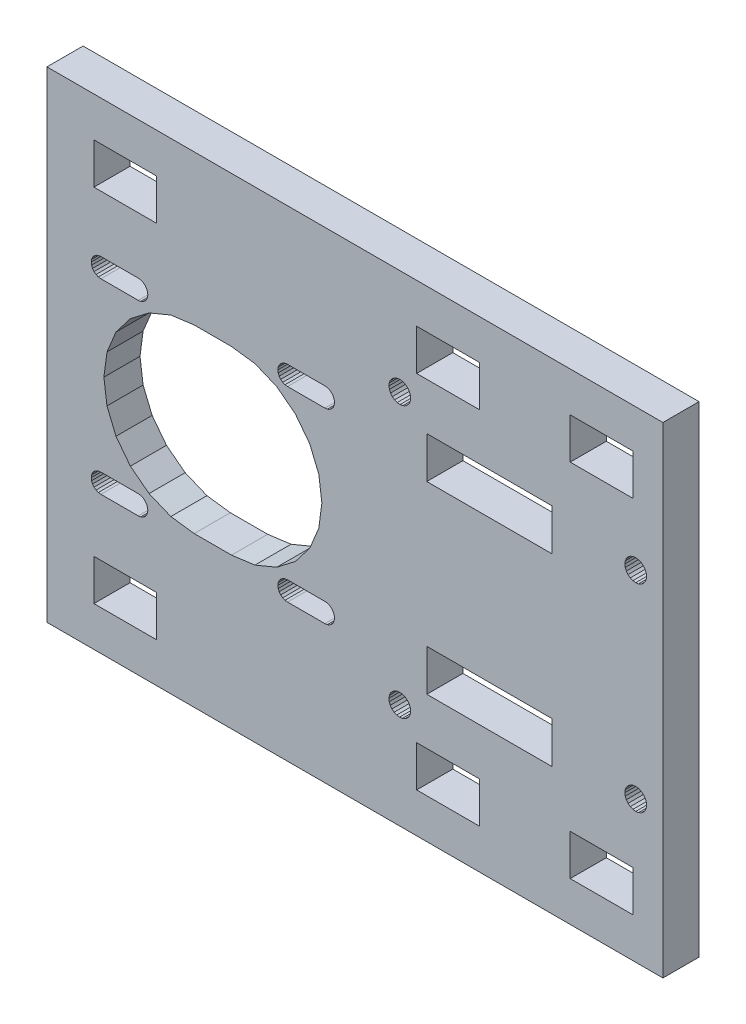
from build123d import *

# Parameters (mm, degrees)
SKETCH1_W           = 102.298269881
SKETCH1_H           = 79.9
SKETCH1_W_2         = 10.4
SKETCH1_H_2         = 6.8
SKETCH1_W_3         = 20.768459162
SKETCH1_H_3         = 6.9
BOSS_EXTRUDE1_DEPTH = 6


with BuildPart() as part:
    # Sketch1 → Boss-Extrude1 (new body)
    with BuildSketch(Plane.XY):
        with Locations((-457.188482006, -325.919095991)):
            Rectangle(SKETCH1_W, SKETCH1_H)
        Polygon((-500.512722428, -309.237725141), (-500.766992224, -309.569095991), (-500.9268329, -309.954985519), (-500.981351578, -310.369095991), (-500.9268329, -310.783206463), (-500.766992224, -311.169095991), (-500.512722428, -311.500466841), (-500.181351578, -311.754736637), (-499.79546205, -311.914577313), (-499.381351578, -311.969095991), (-493.181351578, -311.969095991), (-492.767241106, -311.914577313), (-492.381351578, -311.754736637), (-492.049980728, -311.500466841), (-491.795710932, -311.169095991), (-491.635870256, -310.783206463), (-491.581351578, -310.369095991), (-491.635870256, -309.954985519), (-491.795710932, -309.569095991), (-492.049980728, -309.237725141), (-492.381351578, -308.983455345), (-492.767241106, -308.823614669), (-493.181351578, -308.769095991), (-499.381351578, -308.769095991), (-499.79546205, -308.823614669), (-500.181351578, -308.983455345), align=None, mode=Mode.SUBTRACT)
        with Locations((-495.337616946, -295.969095991)):
            Rectangle(SKETCH1_W_2, SKETCH1_H_2, mode=Mode.SUBTRACT)
        with Locations((-495.337616946, -355.869095991)):
            Rectangle(SKETCH1_W_2, SKETCH1_H_2, mode=Mode.SUBTRACT)
        Polygon((-411.455080535, -307.910250264), (-411.020954816, -307.730429504), (-410.555080535, -307.669095991), (-410.089206254, -307.730429504), (-409.655080535, -307.910250264), (-409.282288329, -308.196303785), (-408.996234808, -308.569095991), (-408.816414048, -309.00322171), (-408.755080535, -309.469095991), (-408.816414048, -309.934970272), (-408.996234808, -310.369095991), (-409.282288329, -310.741888197), (-409.655080535, -311.027941718), (-410.089206254, -311.207762478), (-410.555080535, -311.269095991), (-411.020954816, -311.207762478), (-411.455080535, -311.027941718), (-411.827872741, -310.741888197), (-412.113926262, -310.369095991), (-412.293747022, -309.934970272), (-412.355080535, -309.469095991), (-412.293747022, -309.00322171), (-412.113926262, -308.569095991), (-411.827872741, -308.196303785), align=None, mode=Mode.SUBTRACT)
        with Locations((-441.737616946, -295.969095991)):
            Rectangle(SKETCH1_W_2, SKETCH1_H_2, mode=Mode.SUBTRACT)
        with Locations((-416.237616946, -355.869095991)):
            Rectangle(SKETCH1_W_2, SKETCH1_H_2, mode=Mode.SUBTRACT)
        Polygon((-448.159216053, -347.553850004), (-447.989056618, -347.991852758), (-447.938058681, -348.458971432), (-448.009697666, -348.923372661), (-448.199091494, -349.353408269), (-448.493333289, -349.719772038), (-448.872370959, -349.997496885), (-449.310373713, -350.167656319), (-449.777492387, -350.218654256), (-450.241893616, -350.147015272), (-450.671929224, -349.957621444), (-451.038292993, -349.663379649), (-451.31601784, -349.284341979), (-451.486177274, -348.846339224), (-451.537175211, -348.37922055), (-451.465536227, -347.914819321), (-451.276142399, -347.484783714), (-450.981900604, -347.118419944), (-450.602862934, -346.840695097), (-450.164860179, -346.670535663), (-449.697741505, -346.619537726), (-449.233340276, -346.691176711), (-448.803304669, -346.880570539), (-448.436940899, -347.174812334), align=None, mode=Mode.SUBTRACT)
        Polygon((-469.512722428, -340.237725141), (-469.766992224, -340.569095991), (-469.9268329, -340.954985519), (-469.981351578, -341.369095991), (-469.9268329, -341.783206463), (-469.766992224, -342.169095991), (-469.512722428, -342.500466841), (-469.181351578, -342.754736637), (-468.79546205, -342.914577313), (-468.381351578, -342.969095991), (-462.181351578, -342.969095991), (-461.767241106, -342.914577313), (-461.381351578, -342.754736637), (-461.049980728, -342.500466841), (-460.795710932, -342.169095991), (-460.635870256, -341.783206463), (-460.581351578, -341.369095991), (-460.635870256, -340.954985519), (-460.795710932, -340.569095991), (-461.049980728, -340.237725141), (-461.381351578, -339.983455345), (-461.767241106, -339.823614669), (-462.181351578, -339.769095991), (-468.381351578, -339.769095991), (-468.79546205, -339.823614669), (-469.181351578, -339.983455345), align=None, mode=Mode.SUBTRACT)
        Polygon((-473.799065901, -311.380208597), (-477.681351578, -310.869095991), (-483.881351578, -310.869095991), (-487.763637254, -311.380208597), (-491.381351578, -312.878714934), (-494.487953296, -315.262494273), (-496.871732635, -318.369095991), (-498.370238972, -321.986810315), (-498.881351578, -325.869095991), (-498.370238972, -329.751381668), (-496.871732635, -333.369095991), (-494.487953296, -336.475697709), (-491.381351578, -338.859477048), (-487.763637254, -340.357983385), (-483.881351578, -340.869095991), (-477.681351578, -340.869095991), (-473.799065901, -340.357983385), (-470.181351578, -338.859477048), (-467.07474986, -336.475697709), (-464.690970521, -333.369095991), (-463.192464183, -329.751381668), (-462.681351578, -325.869095991), (-463.192464183, -321.986810315), (-464.690970521, -318.369095991), (-467.07474986, -315.262494273), (-470.181351578, -312.878714934), align=None, mode=Mode.SUBTRACT)
        Polygon((-448.803304669, -304.957621444), (-449.233340276, -305.147015272), (-449.697741505, -305.218654256), (-450.164860179, -305.167656319), (-450.602862934, -304.997496885), (-450.981900604, -304.719772038), (-451.276142399, -304.353408269), (-451.465536227, -303.923372661), (-451.537175211, -303.458971432), (-451.486177274, -302.991852758), (-451.31601784, -302.553850004), (-451.038292993, -302.174812334), (-450.671929224, -301.880570539), (-450.241893616, -301.691176711), (-449.777492387, -301.619537726), (-449.310373713, -301.670535663), (-448.872370959, -301.840695097), (-448.493333289, -302.118419944), (-448.199091494, -302.484783714), (-448.009697666, -302.914819321), (-447.938058681, -303.37922055), (-447.989056618, -303.846339224), (-448.159216053, -304.284341979), (-448.436940899, -304.663379649), align=None, mode=Mode.SUBTRACT)
        Polygon((-491.581351578, -341.369095991), (-491.635870256, -340.954985519), (-491.795710932, -340.569095991), (-492.049980728, -340.237725141), (-492.381351578, -339.983455345), (-492.767241106, -339.823614669), (-493.181351578, -339.769095991), (-499.381351578, -339.769095991), (-499.79546205, -339.823614669), (-500.181351578, -339.983455345), (-500.512722428, -340.237725141), (-500.766992224, -340.569095991), (-500.9268329, -340.954985519), (-500.981351578, -341.369095991), (-500.9268329, -341.783206463), (-500.766992224, -342.169095991), (-500.512722428, -342.500466841), (-500.181351578, -342.754736637), (-499.79546205, -342.914577313), (-499.381351578, -342.969095991), (-493.181351578, -342.969095991), (-492.767241106, -342.914577313), (-492.381351578, -342.754736637), (-492.049980728, -342.500466841), (-491.795710932, -342.169095991), (-491.635870256, -341.783206463), align=None, mode=Mode.SUBTRACT)
        Polygon((-412.293747022, -341.90322171), (-412.113926262, -341.469095991), (-411.827872741, -341.096303785), (-411.455080535, -340.810250264), (-411.020954816, -340.630429504), (-410.555080535, -340.569095991), (-410.089206254, -340.630429504), (-409.655080535, -340.810250264), (-409.282288329, -341.096303785), (-408.996234808, -341.469095991), (-408.816414048, -341.90322171), (-408.755080535, -342.369095991), (-408.816414048, -342.834970272), (-408.996234808, -343.269095991), (-409.282288329, -343.641888197), (-409.655080535, -343.927941718), (-410.089206254, -344.107762478), (-410.555080535, -344.169095991), (-411.020954816, -344.107762478), (-411.455080535, -343.927941718), (-411.827872741, -343.641888197), (-412.113926262, -343.269095991), (-412.293747022, -342.834970272), (-412.355080535, -342.369095991), align=None, mode=Mode.SUBTRACT)
        Polygon((-469.181351578, -311.754736637), (-468.79546205, -311.914577313), (-468.381351578, -311.969095991), (-462.181351578, -311.969095991), (-461.767241106, -311.914577313), (-461.381351578, -311.754736637), (-461.049980728, -311.500466841), (-460.795710932, -311.169095991), (-460.635870256, -310.783206463), (-460.581351578, -310.369095991), (-460.635870256, -309.954985519), (-460.795710932, -309.569095991), (-461.049980728, -309.237725141), (-461.381351578, -308.983455345), (-461.767241106, -308.823614669), (-462.181351578, -308.769095991), (-468.381351578, -308.769095991), (-468.79546205, -308.823614669), (-469.181351578, -308.983455345), (-469.512722428, -309.237725141), (-469.766992224, -309.569095991), (-469.9268329, -309.954985519), (-469.981351578, -310.369095991), (-469.9268329, -310.783206463), (-469.766992224, -311.169095991), (-469.512722428, -311.500466841), align=None, mode=Mode.SUBTRACT)
        with Locations((-434.870848456, -341.219095991)):
            Rectangle(SKETCH1_W_3, SKETCH1_H_3, mode=Mode.SUBTRACT)
        with Locations((-434.870848456, -310.619095991)):
            Rectangle(SKETCH1_W_3, SKETCH1_H_3, mode=Mode.SUBTRACT)
        with Locations((-416.237616946, -295.969095991)):
            Rectangle(SKETCH1_W_2, SKETCH1_H_2, mode=Mode.SUBTRACT)
        with Locations((-441.737616946, -355.869095991)):
            Rectangle(SKETCH1_W_2, SKETCH1_H_2, mode=Mode.SUBTRACT)
    extrude(amount=BOSS_EXTRUDE1_DEPTH)


solid = part.part
